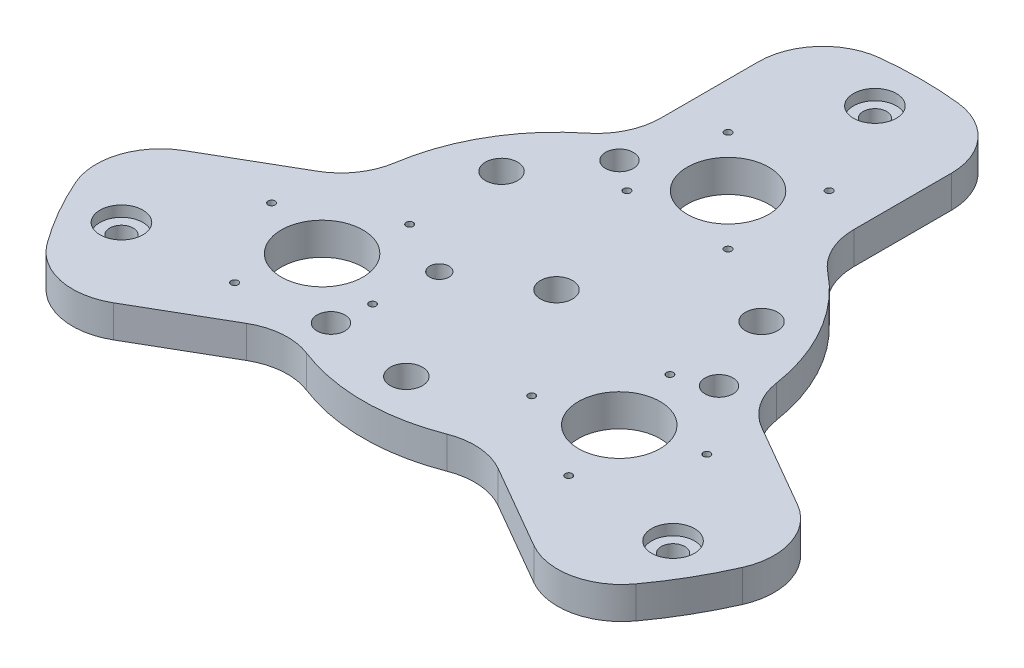
from build123d import *

# Parameters (mm, degrees)
BOSS_EXTRUDE1_DEPTH        = 15
FILLET1_R                  = 30
SKETCH4_R                  = 10
CUT_EXTRUDE1_DEPTH         = 5
M10_CLEARANCE_HOLE1_D      = 11
SKETCH7_R                  = 19.05
CUT_EXTRUDE2_DEPTH         = 16
M4_TAPPED_HOLE1_D          = 3.3
CIRPATTERN2_COUNT          = 3
CIRPATTERN3_COUNT          = 3
M12_CLEARANCE_HOLE1_D      = 13
CIRPATTERN4_COUNT          = 3
F_15_0_15_DIAMETER_HOLE1_D = 15
CIRPATTERN5_COUNT          = 3
F_15_0_15_DIAMETER_HOLE2_D = 15
F_9_0_9_DIAMETER_HOLE1_D   = 9


with BuildPart() as part:
    # Sketch1 → Boss-Extrude1 (new body)
    with BuildSketch(Plane(origin=(0, 0, 0), x_dir=(1, 0, 0), z_dir=(0, 1, 0))):
        with BuildLine():
            ThreePointArc((45, 163.935963108), (0, 170), (-45, 163.935963108))
            Line((-45, 163.935963108), (-45, 77.942286341))
            ThreePointArc((-45, 77.942286341), (-77.942286341, 45), (-90, 0))
            Line((-90, 0), (-164.472708645, -42.996838383))
            ThreePointArc((-164.472708645, -42.996838383), (-147.224318643, -85), (-119.472708645, -120.939124724))
            Line((-119.472708645, -120.939124724), (-45, -77.942286341))
            ThreePointArc((-45, -77.942286341), (0, -90), (45, -77.942286341))
            Line((45, -77.942286341), (119.472708645, -120.939124724))
            ThreePointArc((119.472708645, -120.939124724), (147.224318643, -85), (164.472708645, -42.996838383))
            Line((164.472708645, -42.996838383), (90, 0))
            ThreePointArc((90, 0), (77.942286341, 45), (45, 77.942286341))
            Line((45, 77.942286341), (45, 163.935963108))
        make_face()
    extrude(amount=BOSS_EXTRUDE1_DEPTH)

    # Fillet1
    fillet1_edges = [part.edges().sort_by_distance(p)[0] for p in [
        (-119.472708645, 7.5, 120.939124724),
        (-164.472708645, 7.5, 42.996838383),
        (-90, 7.5, 0),
        (-45, 7.5, -77.942286341),
        (-45, 7.5, -163.935963108),
        (45, 7.5, -163.935963108),
        (45, 7.5, -77.942286341),
        (90, 7.5, 0),
        (164.472708645, 7.5, 42.996838383),
        (119.472708645, 7.5, 120.939124724),
        (45, 7.5, 77.942286341),
        (-45, 7.5, 77.942286341),
    ]]
    fillet(fillet1_edges, radius=FILLET1_R)

    # Sketch4 → Cut-Extrude1 (cut)
    with BuildSketch(Plane(origin=(0, 15, 0), x_dir=(1, 0, 0), z_dir=(0, 1, 0))):
        with Locations((0, 148.5)):
            Circle(SKETCH4_R)
    cut_extrude1 = extrude(amount=-CUT_EXTRUDE1_DEPTH, mode=Mode.SUBTRACT)

    # M10 Clearance Hole1 (through all)
    with Locations(Plane(origin=(0, 15, 0), x_dir=(-1, 0, 0), z_dir=(0, 1, 0))):
        with Locations((0, -148.5)):
            m10_clearance_hole1 = Hole(M10_CLEARANCE_HOLE1_D / 2)

    # Sketch7 → Cut-Extrude2 (cut, through all)
    with BuildSketch(Plane(origin=(0, 15, 0), x_dir=(1, 0, 0), z_dir=(0, 1, 0))):
        with Locations((0, 80)):
            Circle(SKETCH7_R)
    cut_extrude2 = extrude(amount=-CUT_EXTRUDE2_DEPTH, mode=Mode.SUBTRACT)

    # M4 Tapped Hole1 (through all)
    with Locations(Plane(origin=(0, 15, 0), x_dir=(1, 0, 0), z_dir=(0, 1, 0))):
        with Locations((-23.57, 103.57), (23.57, 56.43), (23.57, 103.57), (-23.57, 56.43)):
            m4_tapped_hole1 = Hole(M4_TAPPED_HOLE1_D / 2)

    # CirPattern2: Cut-Extrude2, M4 Tapped Hole1 ×3 about axis
    cirpattern2_axis = Axis((0, 0, 0), (0, 1, 0))
    for i in range(1, CIRPATTERN2_COUNT):
        add(cut_extrude2.rotate(cirpattern2_axis, i * 360 / CIRPATTERN2_COUNT), mode=Mode.SUBTRACT)
        add(m4_tapped_hole1.rotate(cirpattern2_axis, i * 360 / CIRPATTERN2_COUNT), mode=Mode.SUBTRACT)

    # CirPattern3: Cut-Extrude1, M10 Clearance Hole1 ×3 about axis
    cirpattern3_axis = Axis((0, 0, 0), (0, 1, 0))
    for i in range(1, CIRPATTERN3_COUNT):
        add(cut_extrude1.rotate(cirpattern3_axis, i * 360 / CIRPATTERN3_COUNT), mode=Mode.SUBTRACT)
        add(m10_clearance_hole1.rotate(cirpattern3_axis, i * 360 / CIRPATTERN3_COUNT), mode=Mode.SUBTRACT)

    # M12 Clearance Hole1 (through all)
    with Locations(Plane(origin=(0, 15, 0), x_dir=(1, 0, 0), z_dir=(0, 1, 0))):
        with Locations((-39.17442065, -65.983537492)):
            m12_clearance_hole1 = Hole(M12_CLEARANCE_HOLE1_D / 2)

    # CirPattern4: M12 Clearance Hole1 ×3 about axis
    cirpattern4_axis = Axis((0, 0, 0), (0, 1, 0))
    for i in range(1, CIRPATTERN4_COUNT):
        add(m12_clearance_hole1.rotate(cirpattern4_axis, i * 360 / CIRPATTERN4_COUNT), mode=Mode.SUBTRACT)

    # Ø15.0 (15) Diameter Hole1 (through all)
    with Locations(Plane(origin=(0, 0, 0), x_dir=(-1, 0, 0), z_dir=(0, -1, 0))):
        with Locations((0, -70)):
            f_15_0_15_diameter_hole1 = Hole(F_15_0_15_DIAMETER_HOLE1_D / 2)

    # CirPattern5: Ø15.0 (15) Diameter Hole1 ×3 about axis
    cirpattern5_axis = Axis((0, 0, 0), (0, 1, 0))
    for i in range(1, CIRPATTERN5_COUNT):
        add(f_15_0_15_diameter_hole1.rotate(cirpattern5_axis, i * 360 / CIRPATTERN5_COUNT), mode=Mode.SUBTRACT)

    # Ø15.0 (15) Diameter Hole2 (through all)
    with Locations(Plane(origin=(0, 0, 0), x_dir=(-1, 0, 0), z_dir=(0, -1, 0))):
        with Locations((0, 0)):
            Hole(F_15_0_15_DIAMETER_HOLE2_D / 2)

    # Ø9.0 (9) Diameter Hole1 (through all)
    with Locations(Plane(origin=(0, 0, 0), x_dir=(-1, 0, 0), z_dir=(0, -1, 0))):
        with Locations((34.641016151, -20)):
            Hole(F_9_0_9_DIAMETER_HOLE1_D / 2)


solid = part.part
